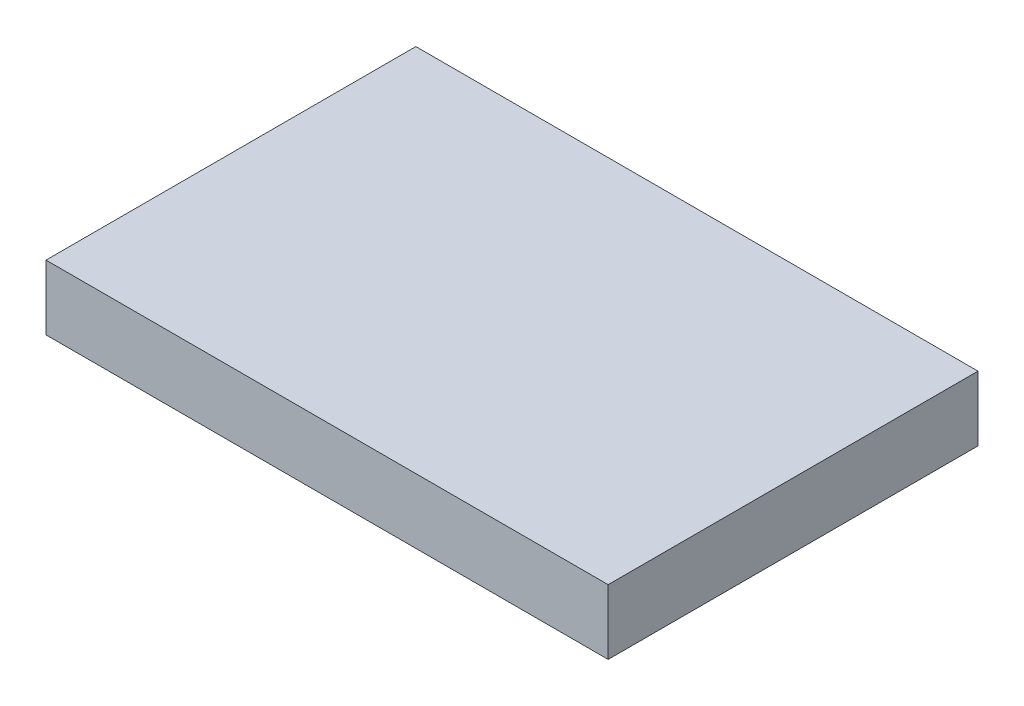
from build123d import *

# Parameters (mm, degrees)
SKETCH1_W           = 82.46
SKETCH1_H           = 54.25
BOSS_EXTRUDE1_DEPTH = 9.5


with BuildPart() as part:
    # Sketch1 → Boss-Extrude1 (new body)
    with BuildSketch(Plane(origin=(0, 0, 0), x_dir=(1, 0, 0), z_dir=(0, 1, 0))):
        with Locations((41.23, -27.125)):
            Rectangle(SKETCH1_W, SKETCH1_H)
    extrude(amount=BOSS_EXTRUDE1_DEPTH)


solid = part.part
